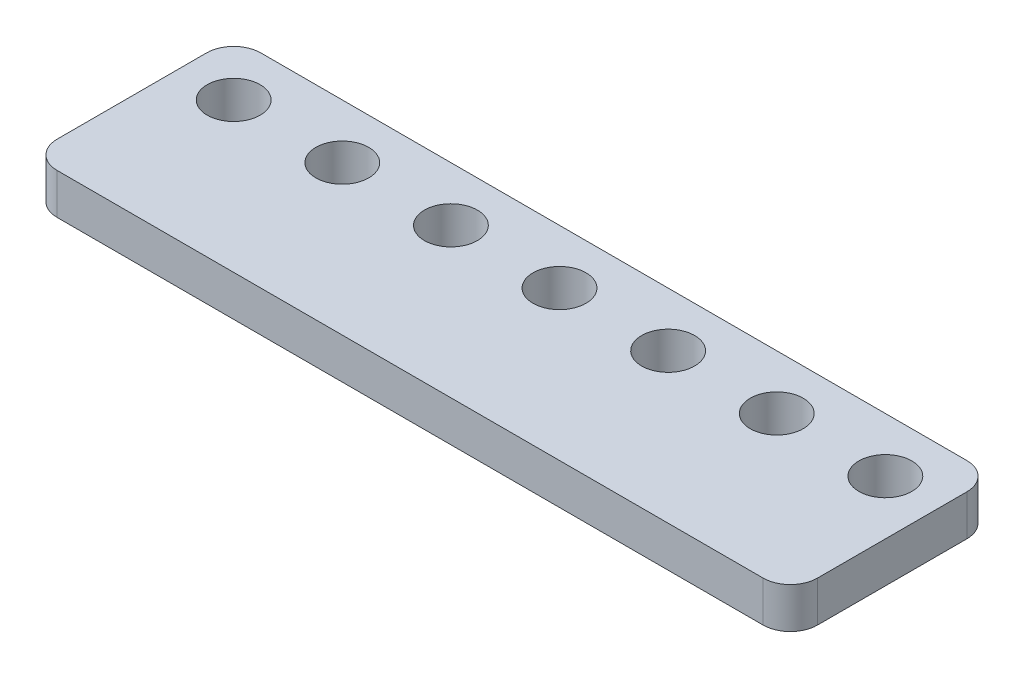
from build123d import *

# Parameters (mm, degrees)
BOSS_EXTRUDE1_DEPTH = 3
SKETCH2_R           = 1.95
CUT_EXTRUDE1_DEPTH  = 4


with BuildPart() as part:
    # Sketch1 → Boss-Extrude1 (new body)
    with BuildSketch(Plane(origin=(0, 0, 0), x_dir=(1, 0, 0), z_dir=(0, 1, 0))):
        with BuildLine():
            Line((-54, 0), (-2, 0))
            ThreePointArc((-2, 0), (-0.585786438, -0.585786438), (0, -2))
            Line((0, -2), (0, -13))
            ThreePointArc((0, -13), (-0.585786438, -14.414213562), (-2, -15))
            Line((-2, -15), (-54, -15))
            ThreePointArc((-54, -15), (-55.414213562, -14.414213562), (-56, -13))
            Line((-56, -13), (-56, -2))
            ThreePointArc((-56, -2), (-55.414213562, -0.585786438), (-54, 0))
        make_face()
    extrude(amount=BOSS_EXTRUDE1_DEPTH)

    # Sketch2 → Cut-Extrude1 (cut, through all)
    with BuildSketch(Plane(origin=(0, 3, 0), x_dir=(1, 0, 0), z_dir=(0, 1, 0))):
        with Locations((-4, -4)):
            Circle(SKETCH2_R)
        with Locations((-12, -4)):
            Circle(SKETCH2_R)
        with Locations((-76, -4)):
            Circle(SKETCH2_R)
        with Locations((-68, -4)):
            Circle(SKETCH2_R)
        with Locations((-60, -4)):
            Circle(SKETCH2_R)
        with Locations((-52, -4)):
            Circle(SKETCH2_R)
        with Locations((-44, -4)):
            Circle(SKETCH2_R)
        with Locations((-36, -4)):
            Circle(SKETCH2_R)
        with Locations((-28, -4)):
            Circle(SKETCH2_R)
        with Locations((-20, -4)):
            Circle(SKETCH2_R)
    extrude(amount=-CUT_EXTRUDE1_DEPTH, mode=Mode.SUBTRACT)


solid = part.part
